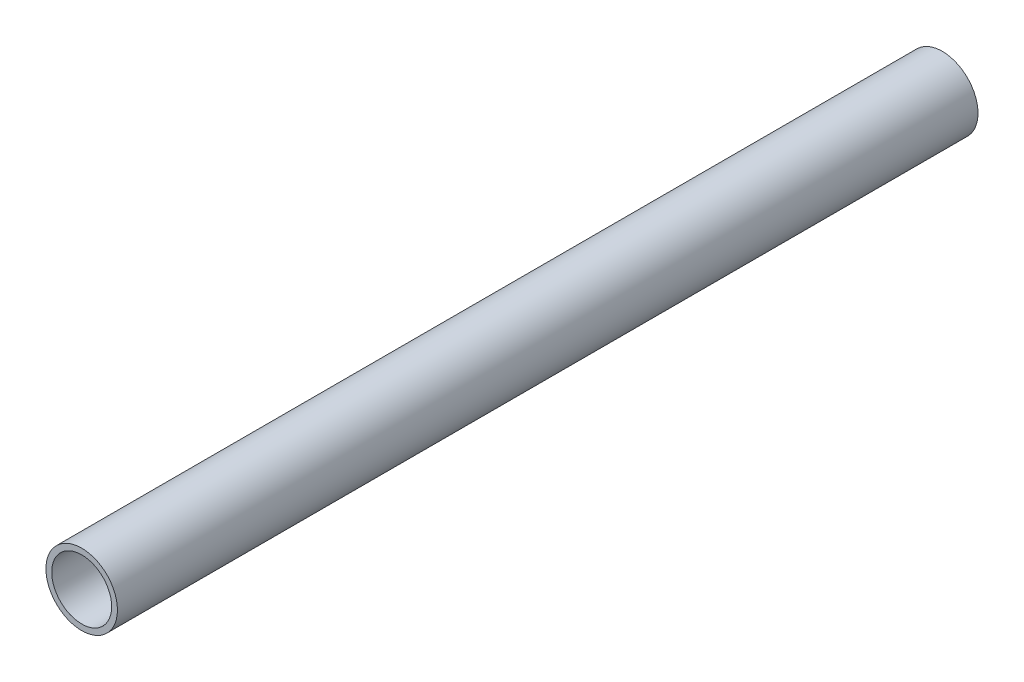
from build123d import *

# Parameters (mm, degrees)
SZKIC1_R                         = 8.35
SZKIC1_R_2                       = 7
DODANIE_WYCI_GNI_CIE1_DEPTH      = 199
DODANIE_WYCI_GNI_CIE1_DEPTH_BACK = 2


with BuildPart() as part:
    # Szkic1 → Dodanie-wyci_gni_cie1 (new body, two sides)
    with BuildSketch(Plane.XY) as dodanie_wyci_gni_cie1_sk:
        Circle(SZKIC1_R)
        Circle(SZKIC1_R_2, mode=Mode.SUBTRACT)
    extrude(amount=DODANIE_WYCI_GNI_CIE1_DEPTH)
    extrude(dodanie_wyci_gni_cie1_sk.sketch, amount=-DODANIE_WYCI_GNI_CIE1_DEPTH_BACK)


solid = part.part
